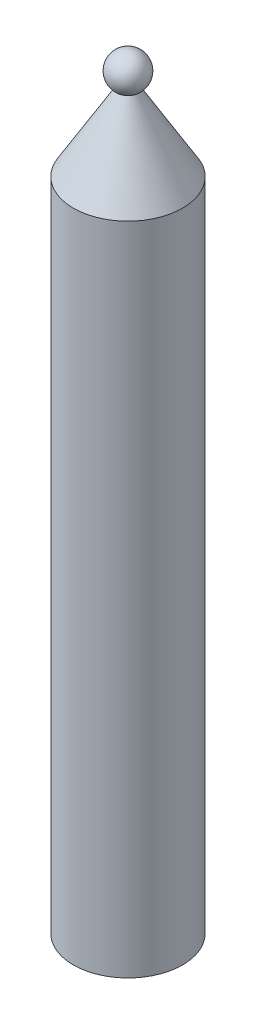
from build123d import *


with BuildPart() as part:
    # Sketch3 → Revolve1 (revolve)
    with BuildSketch(Plane.XY):
        with BuildLine():
            Line((0, 0), (-10, 0))
            Line((-10, 0), (-10, 120))
            Line((-10, 120), (-1.652915155, 134))
            ThreePointArc((-1.652915155, 134), (-3.11175708, 137.629567697), (0, 140))
            Line((0, 140), (0, 0))
        make_face()
    revolve(axis=Axis((0, 140, 0), (0, -1, 0)))

    # Sketch4 → Cut-Revolve1 (revolve, cut)
    with BuildSketch(Plane.XY):
        Polygon((0, 0), (5, 0), (5, 110), (0, 120), align=None)
    revolve(axis=Axis((0, 120, 0), (0, -1, 0)), mode=Mode.SUBTRACT)


solid = part.part
